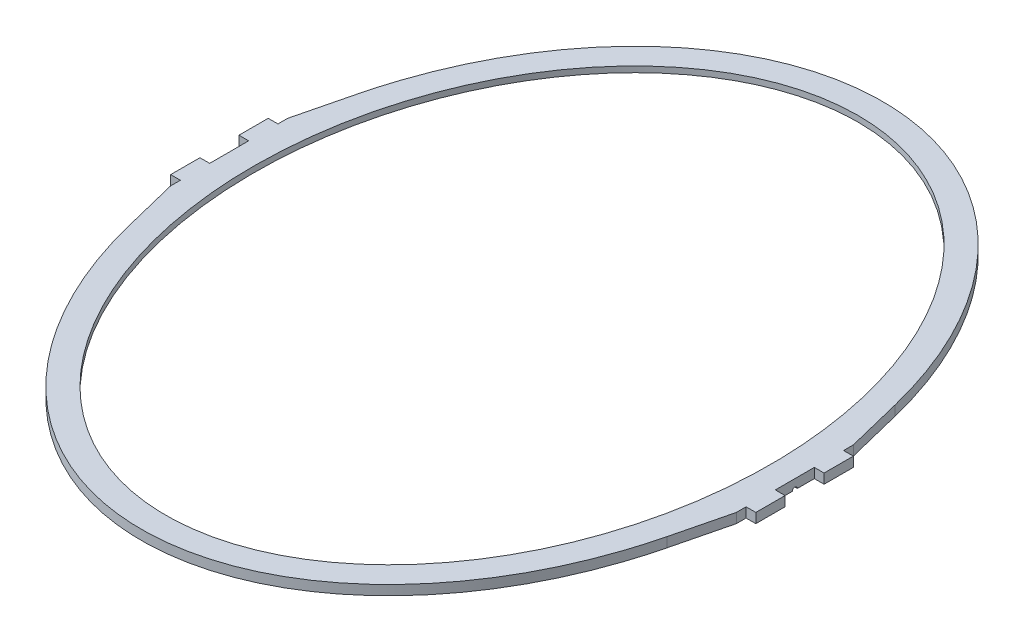
from build123d import *

# Parameters (mm, degrees)
SKETCH1_RX          = 355
SKETCH1_RY          = 265
BOSS_EXTRUDE1_DEPTH = 10
SKETCH2_RX          = 365
SKETCH2_RY          = 275
SKETCH2_RX_2        = 355
SKETCH2_RY_2        = 265
CUT_EXTRUDE1_DEPTH  = 4
CUT_EXTRUDE4_DEPTH  = 10
CUT_EXTRUDE5_DEPTH  = 10


with BuildPart() as part:
    # Sketch1 → Boss-Extrude1 (new body)
    with BuildSketch(Plane(origin=(0, 0, 0), x_dir=(1, 0, 0), z_dir=(0, 1, 0))):
        with BuildLine():
            Line((-290, 60), (-275.891891892, 117.081081081))
            add(Edge.make_bspline(
                [(275.891891892, 117.081081081), (0, 1233.333333333), (-275.891891892, 117.081081081)],
                knots=[5.025592734, 5.025592734, 5.025592734, 7.54077788, 7.54077788, 7.54077788], degree=2, weights=[1, 0.308108108, 1]))
            Line((275.891891892, 117.081081081), (290, 60))
            Line((290, 60), (290, 50))
            Line((290, 50), (300, 50))
            Line((300, 50), (300, 20))
            Line((300, 20), (290, 20))
            Line((290, 20), (290, -20))
            Line((290, -20), (300, -20))
            Line((300, -20), (300, -50))
            Line((300, -50), (290, -50))
            Line((290, -50), (290, -60))
            Line((290, -60), (275.891891892, -117.081081081))
            add(Edge.make_bspline(
                [(-275.891891892, -117.081081081), (0, -1233.333333333), (275.891891892, -117.081081081)],
                knots=[5.025592734, 5.025592734, 5.025592734, 7.54077788, 7.54077788, 7.54077788], degree=2, weights=[1, 0.308108108, 1]))
            Line((-275.891891892, -117.081081081), (-290, -60))
            Line((-290, -60), (-290, -50))
            Line((-290, -50), (-300, -50))
            Line((-300, -50), (-300, -20))
            Line((-300, -20), (-290, -20))
            Line((-290, -20), (-290, 20))
            Line((-290, 20), (-300, 20))
            Line((-300, 20), (-300, 50))
            Line((-300, 50), (-290, 50))
            Line((-290, 50), (-290, 60))
        make_face()
        with Locations(Location((0, 0), (0, 0, 90))):
            Ellipse(SKETCH1_RX, SKETCH1_RY, mode=Mode.SUBTRACT)
    extrude(amount=BOSS_EXTRUDE1_DEPTH)

    # Sketch2 → Cut-Extrude1 (cut)
    with BuildSketch(Plane.XZ):
        with Locations(Location((0, 0), (0, 0, 90))):
            Ellipse(SKETCH2_RX, SKETCH2_RY)
        with Locations(Location((0, 0), (0, 0, 90))):
            Ellipse(SKETCH2_RX_2, SKETCH2_RY_2, mode=Mode.SUBTRACT)
    extrude(amount=-CUT_EXTRUDE1_DEPTH, mode=Mode.SUBTRACT)

    # Sketch4 → Cut-Extrude4 (cut)
    with BuildSketch(Plane.ZY.offset(290)):
        with BuildLine():
            Line((-2.5, 0), (2.5, 0))
            ThreePointArc((2.5, 0), (0, 2.5), (-2.5, 0))
        make_face()
    extrude(amount=-CUT_EXTRUDE4_DEPTH, mode=Mode.SUBTRACT)

    # Sketch5 → Cut-Extrude5 (cut)
    with BuildSketch(Plane(origin=(290, 0, 0), x_dir=(0, 0, -1), z_dir=(1, 0, 0))):
        with BuildLine():
            Line((-2.5, 0), (2.5, 0))
            ThreePointArc((2.5, 0), (0, 2.5), (-2.5, 0))
        make_face()
    extrude(amount=-CUT_EXTRUDE5_DEPTH, mode=Mode.SUBTRACT)


solid = part.part
